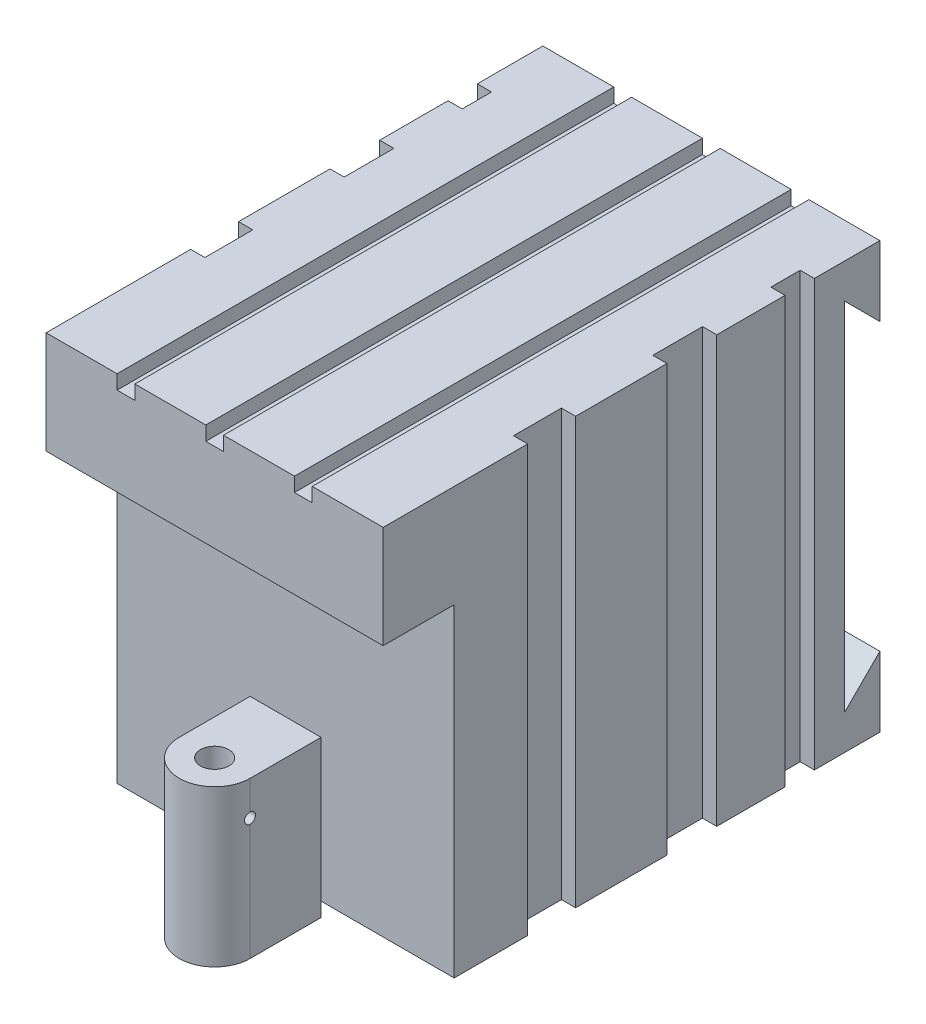
from build123d import *

# Parameters (mm, degrees)
SKETCH1_W                = 50
SKETCH1_H                = 70
BOSS_EXTRUDE1_DEPTH      = 60
CUT_EXTRUDE1_DEPTH       = 60
SKETCH4_W                = 2.5
SKETCH4_H                = 2
SKETCH4_H_2              = 60
CUT_EXTRUDE2_DEPTH       = 95
SKETCH7_W                = 47.5
SKETCH7_H                = 45.554164346
CUT_EXTRUDE3_DEPTH       = 10
SKETCH8_R                = 2
BOSS_EXTRUDE2_DEPTH      = 2
BOSS_EXTRUDE2_DEPTH_BACK = 20
SKETCH9_W                = 6.754259693
SKETCH9_H                = 60
SKETCH9_W_2              = 7.009150451
SKETCH9_W_3              = 4.127603145
CUT_EXTRUDE4_DEPTH       = 2
SKETCH10_W               = 2
SKETCH10_H               = 4.127603145
SKETCH10_H_2             = 7.009150451
SKETCH10_H_3             = 6.754259693
CUT_EXTRUDE5_DEPTH       = 71
SKETCH11_R               = 0.75
CUT_EXTRUDE6_DEPTH       = 4


with BuildPart() as part:
    # Sketch1 → Boss-Extrude1 (new body)
    with BuildSketch(Plane(origin=(0, 0, 0), x_dir=(1, 0, 0), z_dir=(0, 1, 0))):
        with Locations((-20.864146805, -15.987939145)):
            Rectangle(SKETCH1_W, SKETCH1_H)
    extrude(amount=BOSS_EXTRUDE1_DEPTH)

    # Sketch2 → Cut-Extrude1 (cut)
    with BuildSketch(Plane(origin=(4.135853195, 0, 0), x_dir=(0, 0, -1), z_dir=(1, 0, 0))):
        Polygon((19.012060855, 50.122083557), (14.012060855, 55.122083557), (14.012060855, 4.877916443), (19.012060855, 9.877916443), align=None)
    extrude(amount=-CUT_EXTRUDE1_DEPTH, mode=Mode.SUBTRACT)

    # Sketch4 → Cut-Extrude2 (cut)
    with BuildSketch(Plane.XY.offset(50.987939145)):
        with Locations((-34.614146805, 59)):
            Rectangle(SKETCH4_W, SKETCH4_H)
        with Locations((-22.114146805, 59)):
            Rectangle(SKETCH4_W, SKETCH4_H)
        with Locations((-9.614146805, 59)):
            Rectangle(SKETCH4_W, SKETCH4_H)
        with Locations((2.885853195, 30)):
            Rectangle(SKETCH4_W, SKETCH4_H_2)
    extrude(amount=-CUT_EXTRUDE2_DEPTH, mode=Mode.SUBTRACT)

    # Sketch7 → Cut-Extrude3 (cut)
    with BuildSketch(Plane.XY.offset(50.987939145)):
        with Locations((-22.114146805, 22.777082173)):
            Rectangle(SKETCH7_W, SKETCH7_H)
    extrude(amount=-CUT_EXTRUDE3_DEPTH, mode=Mode.SUBTRACT)

    # Sketch8 → Boss-Extrude2 (add, two sides)
    with BuildSketch(Plane.XZ) as boss_extrude2_sk:
        with BuildLine():
            Line((-17.114146805, 40.987939145), (-27.114146805, 40.987939145))
            Line((-27.114146805, 40.987939145), (-27.114146805, 50.987939145))
            ThreePointArc((-27.114146805, 50.987939145), (-22.114146805, 55.987939145), (-17.114146805, 50.987939145))
            Line((-17.114146805, 50.987939145), (-17.114146805, 40.987939145))
        make_face()
        with Locations((-22.114146805, 50.987939145)):
            Circle(SKETCH8_R, mode=Mode.SUBTRACT)
    extrude(amount=BOSS_EXTRUDE2_DEPTH)
    extrude(boss_extrude2_sk.sketch, amount=-BOSS_EXTRUDE2_DEPTH_BACK)

    # Sketch9 → Cut-Extrude4 (cut)
    with BuildSketch(Plane(origin=(1.635853195, 0, 0), x_dir=(0, 0, -1), z_dir=(1, 0, 0))):
        with Locations((-27.243460969, 30)):
            Rectangle(SKETCH9_W, SKETCH9_H)
        with Locations((-7.48336392, 30)):
            Rectangle(SKETCH9_W_2, SKETCH9_H)
        with Locations((7.716086886, 30)):
            Rectangle(SKETCH9_W_3, SKETCH9_H)
    extrude(amount=-CUT_EXTRUDE4_DEPTH, mode=Mode.SUBTRACT)

    # Sketch10 → Cut-Extrude5 (cut)
    with BuildSketch(Plane(origin=(0, 60, 0), x_dir=(1, 0, 0), z_dir=(0, 1, 0))):
        with Locations((-44.864146805, 7.716086886)):
            Rectangle(SKETCH10_W, SKETCH10_H)
        with Locations((-44.864146805, -7.48336392)):
            Rectangle(SKETCH10_W, SKETCH10_H_2)
        with Locations((-44.864146805, -27.243460969)):
            Rectangle(SKETCH10_W, SKETCH10_H_3)
    extrude(amount=-CUT_EXTRUDE5_DEPTH, mode=Mode.SUBTRACT)

    # Sketch11 → Cut-Extrude6 (cut)
    with BuildSketch(Plane(origin=(-17.114146805, 0, 0), x_dir=(0, 0, -1), z_dir=(1, 0, 0))):
        with Locations((-50.987939145, 15.146186294)):
            Circle(SKETCH11_R)
    extrude(amount=-CUT_EXTRUDE6_DEPTH, mode=Mode.SUBTRACT)


solid = part.part
